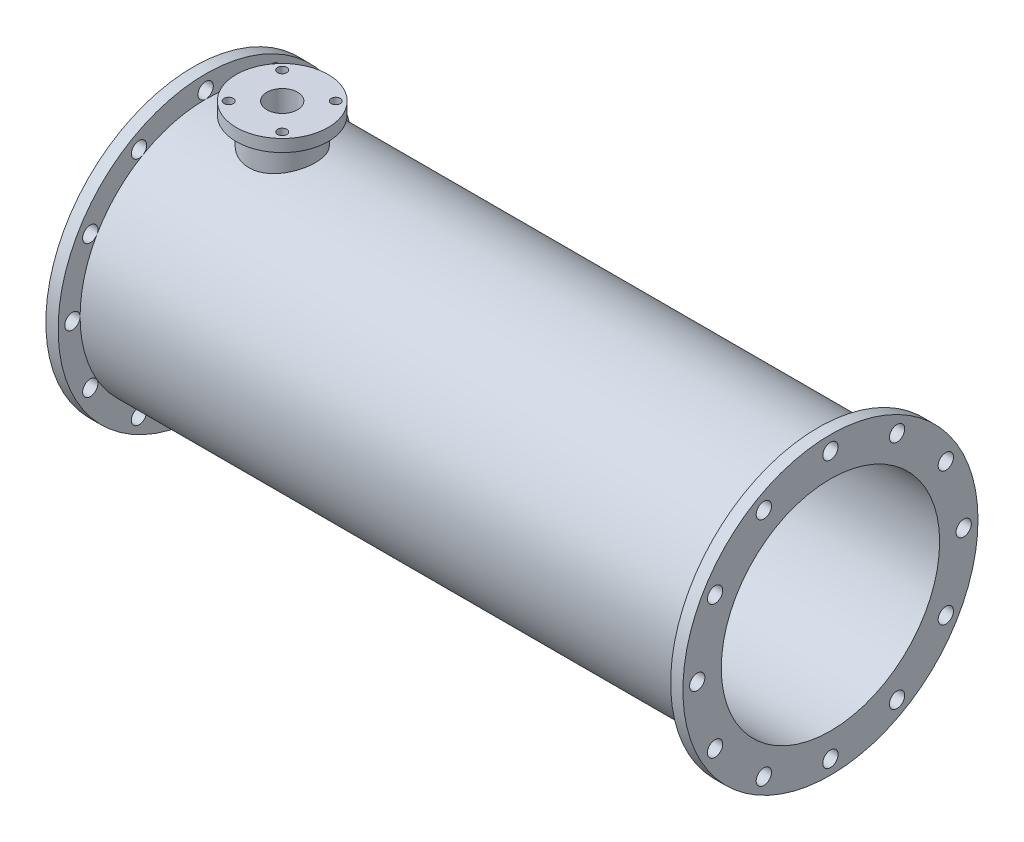
from build123d import *

# Parameters (mm, degrees)
SKETCH1_R            = 2408.838280344
SKETCH1_R_2          = 1782.540327454
SKETCH1_R_3          = 125
BOSS_EXTRUDE1_DEPTH  = 200
SKETCH2_R            = 2050
SKETCH2_R_2          = 1782.540327454
BOSS_EXTRUDE3_DEPTH  = 2500
SKETCH4_R            = 750
SKETCH4_R_2          = 75
BOSS_EXTRUDE15_DEPTH = 200
BOSS_EXTRUDE17_START = -673.261306
SKETCH11_R           = 543.142831057
SKETCH11_R_2         = 250
BOSS_EXTRUDE17_DEPTH = 473.261306
SKETCH12_R           = 250
CUT_EXTRUDE4_DEPTH   = 1310
SKETCH14_R           = 2050
SKETCH14_R_2         = 1782.540327454
BOSS_EXTRUDE18_DEPTH = 7500


with BuildPart() as part:
    # Sketch1 → Boss-Extrude1 (new body)
    with BuildSketch(Plane(origin=(0, 0, 0), x_dir=(0, 0, -1), z_dir=(1, 0, 0))):
        Circle(SKETCH1_R)
        Circle(SKETCH1_R_2, mode=Mode.SUBTRACT)
        with Locations((0, 2175)):
            Circle(SKETCH1_R_3, mode=Mode.SUBTRACT)
        with Locations((1087.5, 1883.605253231)):
            Circle(SKETCH1_R_3, mode=Mode.SUBTRACT)
        with Locations((1883.605253231, 1087.5)):
            Circle(SKETCH1_R_3, mode=Mode.SUBTRACT)
        with Locations((2175, 0)):
            Circle(SKETCH1_R_3, mode=Mode.SUBTRACT)
        with Locations((1883.605253231, -1087.5)):
            Circle(SKETCH1_R_3, mode=Mode.SUBTRACT)
        with Locations((1087.5, -1883.605253231)):
            Circle(SKETCH1_R_3, mode=Mode.SUBTRACT)
        with Locations((0, -2175)):
            Circle(SKETCH1_R_3, mode=Mode.SUBTRACT)
        with Locations((-1087.5, -1883.605253231)):
            Circle(SKETCH1_R_3, mode=Mode.SUBTRACT)
        with Locations((-1883.605253231, -1087.5)):
            Circle(SKETCH1_R_3, mode=Mode.SUBTRACT)
        with Locations((-2175, 0)):
            Circle(SKETCH1_R_3, mode=Mode.SUBTRACT)
        with Locations((-1883.605253231, 1087.5)):
            Circle(SKETCH1_R_3, mode=Mode.SUBTRACT)
        with Locations((-1087.5, 1883.605253231)):
            Circle(SKETCH1_R_3, mode=Mode.SUBTRACT)
    boss_extrude1 = extrude(amount=BOSS_EXTRUDE1_DEPTH)

    # Sketch2 → Boss-Extrude3 (add)
    with BuildSketch(Plane(origin=(200, 0, 0), x_dir=(0, 0, -1), z_dir=(1, 0, 0))):
        Circle(SKETCH2_R)
        Circle(SKETCH2_R_2, mode=Mode.SUBTRACT)
    extrude(amount=BOSS_EXTRUDE3_DEPTH)



with BuildPart() as body_2:
    # Sketch4 → Boss-Extrude15 (new body)
    with BuildSketch(Plane(origin=(0, 2650, 0), x_dir=(1, 0, 0), z_dir=(0, 1, 0))):
        with Locations((1450, 0)):
            Circle(SKETCH4_R)
        with Locations((1887.092987583, 437.092987583)):
            Circle(SKETCH4_R_2, mode=Mode.SUBTRACT)
        with Locations((1887.092987583, -437.092987583)):
            Circle(SKETCH4_R_2, mode=Mode.SUBTRACT)
        with Locations((1012.907012417, -437.092987583)):
            Circle(SKETCH4_R_2, mode=Mode.SUBTRACT)
        with Locations((1012.907012417, 437.092987583)):
            Circle(SKETCH4_R_2, mode=Mode.SUBTRACT)
    extrude(amount=-BOSS_EXTRUDE15_DEPTH)


with BuildPart() as part_1:
    add(part.part)

    add(body_2.part)  # Boss-Extrude17 merges body 2
    # Sketch11 → Boss-Extrude17 (add)
    with BuildSketch(Plane(origin=(0, 2650, 0), x_dir=(1, 0, 0), z_dir=(0, 1, 0)).offset(BOSS_EXTRUDE17_START)):
        with Locations((1450, 0)):
            Circle(SKETCH11_R)
        with Locations((1450, 0)):
            Circle(SKETCH11_R_2, mode=Mode.SUBTRACT)
    extrude(amount=BOSS_EXTRUDE17_DEPTH)

    # Sketch12 → Cut-Extrude4 (cut)
    with BuildSketch(Plane(origin=(0, 2650, 0), x_dir=(1, 0, 0), z_dir=(0, 1, 0))):
        with Locations((1450, 0)):
            Circle(SKETCH12_R)
    extrude(amount=-CUT_EXTRUDE4_DEPTH, mode=Mode.SUBTRACT)

    # Sketch14 → Boss-Extrude18 (add)
    with BuildSketch(Plane(origin=(2700, 0, 0), x_dir=(0, 0, -1), z_dir=(1, 0, 0))):
        Circle(SKETCH14_R)
        Circle(SKETCH14_R_2, mode=Mode.SUBTRACT)
    extrude(amount=BOSS_EXTRUDE18_DEPTH)

    # Mirror5: Boss-Extrude1 across plane
    add(boss_extrude1.mirror(Plane(origin=(5200, 0, 0), x_dir=(0, 0, 1), z_dir=(1, 0, 0))))


solid = part_1.part
